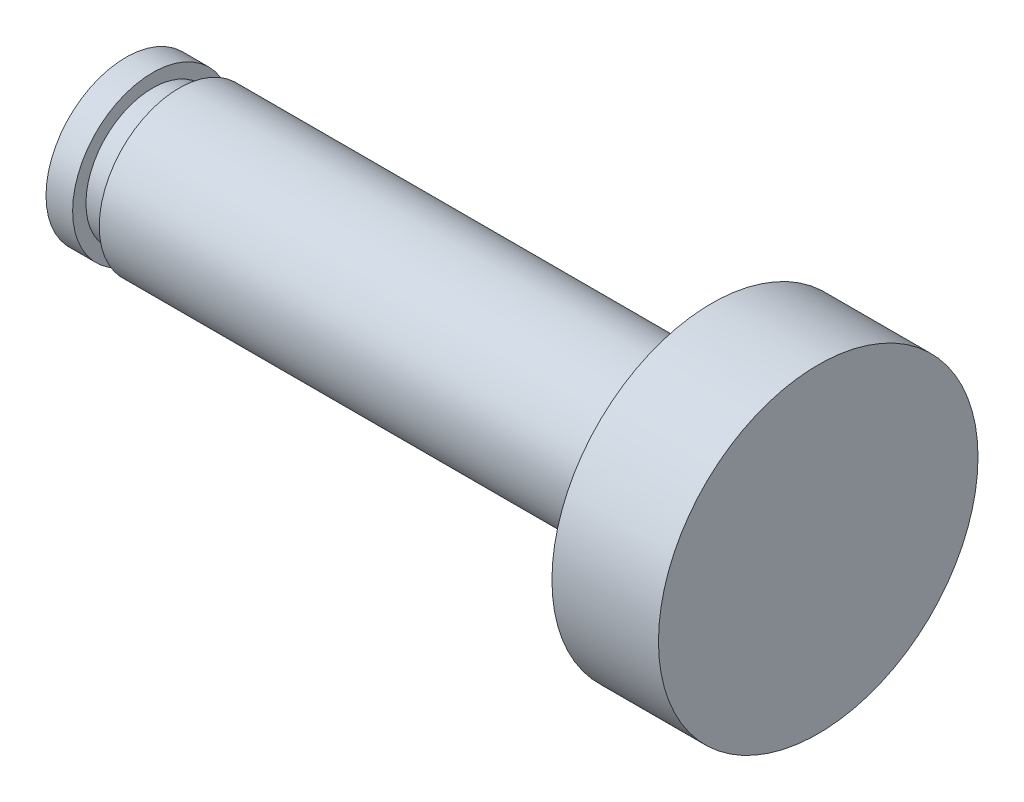
from build123d import *


with BuildPart() as part:
    # Sketch1 → Revolve1 (revolve)
    with BuildSketch(Plane(origin=(0, 0, 0), x_dir=(1, 0, 0), z_dir=(0, 1, 0))):
        Polygon((0, 0), (13, 0), (13, 3), (11, 3), (11, 1.5), (1, 1.5), (1, 1.25), (0.5, 1.25), (0.5, 1.5), (0, 1.5), align=None)
    revolve(axis=Axis((0, 0, 0), (1, 0, 0)))


solid = part.part
